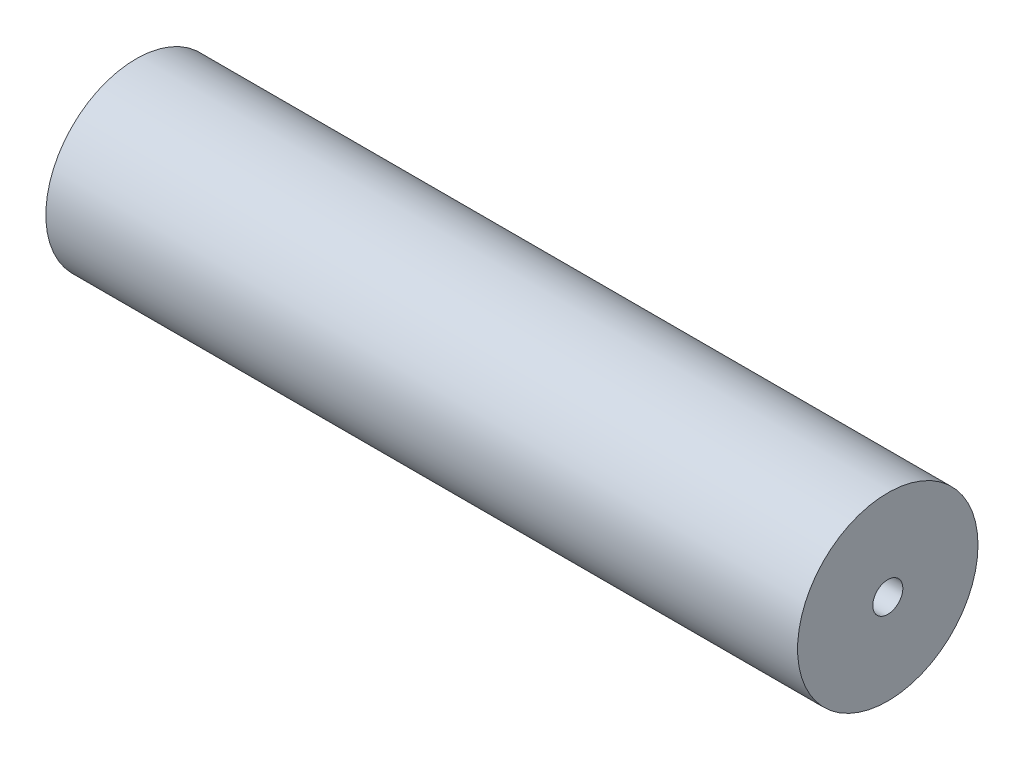
from build123d import *

# Parameters (mm, degrees)
SKETCH2_R           = 30
SKETCH2_R_2         = 5
BOSS_EXTRUDE1_DEPTH = 250


with BuildPart() as part:
    # Sketch2 → Boss-Extrude1 (new body)
    with BuildSketch(Plane(origin=(0, 0, 0), x_dir=(0, 0, -1), z_dir=(1, 0, 0))):
        Circle(SKETCH2_R)
        Circle(SKETCH2_R_2, mode=Mode.SUBTRACT)
    extrude(amount=BOSS_EXTRUDE1_DEPTH)


solid = part.part
